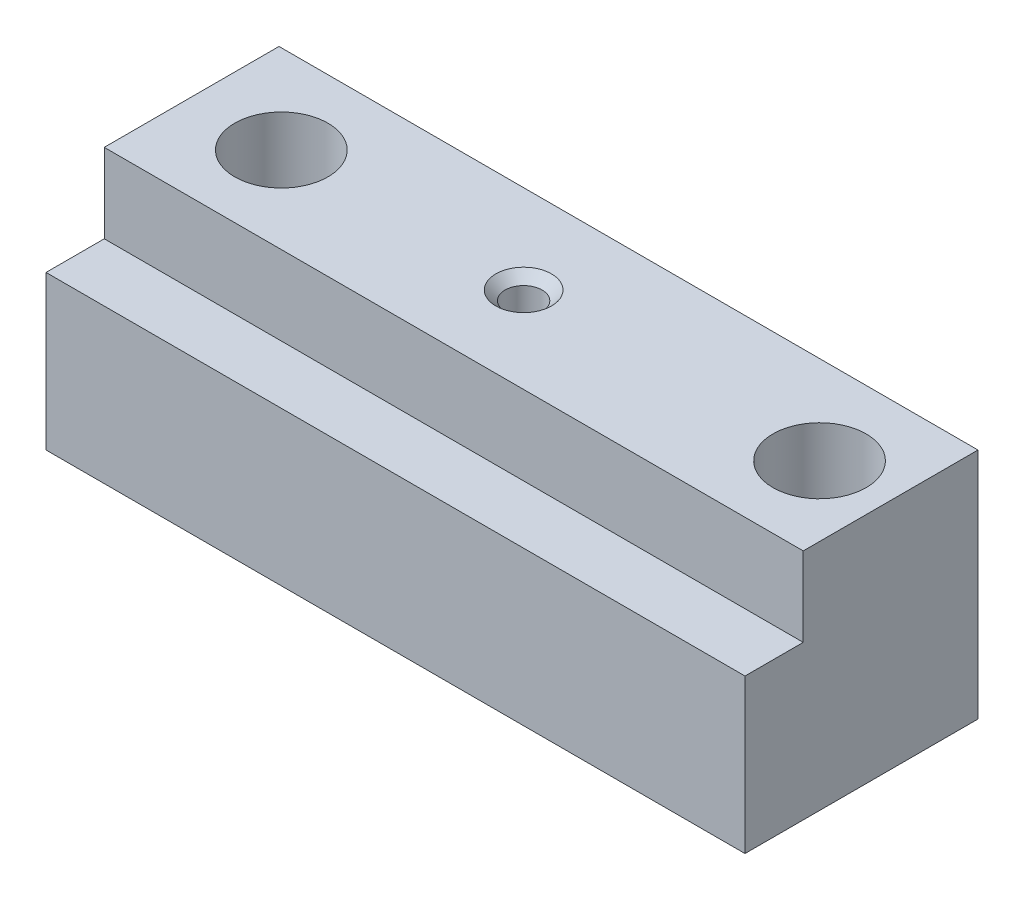
from build123d import *

# Parameters (mm, degrees)
BOSS_EXTRUDE1_DEPTH      = 38.1
BOSS_EXTRUDE1_DEPTH_BACK = 38.1
SKETCH2_R                = 5.08
CUT_EXTRUDE1_DEPTH       = 19.05
F_10_32_TAPPED_HOLE2_D   = 4.0386
CHAMFER5_SIZE            = 1.016
CHAMFER6_SIZE            = 1.016


with BuildPart() as part:
    # Sketch1 → Boss-Extrude1 (new, two sides: drawn at the far end of the back side and taken through both)
    with BuildSketch(Plane(origin=(0, 0, 0), x_dir=(0, 0, -1), z_dir=(1, 0, 0)).offset(-BOSS_EXTRUDE1_DEPTH_BACK)):
        Polygon((0, 0), (-6.35, 0), (-6.35, -16.764), (19.05, -16.764), (19.05, 8.636), (0, 8.636), align=None)
    extrude(amount=BOSS_EXTRUDE1_DEPTH + BOSS_EXTRUDE1_DEPTH_BACK)

    # Sketch2 → Cut-Extrude1 (cut)
    with BuildSketch(Plane(origin=(0, 8.636, 0), x_dir=(1, 0, 0), z_dir=(0, 1, 0))):
        with Locations((-28.194, 9.398)):
            Circle(SKETCH2_R)
        with Locations((30.48, 9.398)):
            Circle(SKETCH2_R)
    extrude(amount=-CUT_EXTRUDE1_DEPTH, mode=Mode.SUBTRACT)

    # 10-32 Tapped Hole2 (through all)
    with Locations(Plane(origin=(-1.778, 8.636, -9.398), x_dir=(0, 0, 1), z_dir=(0, 1, 0))):
        with Locations((0, 0)):
            Hole(F_10_32_TAPPED_HOLE2_D / 2)

    # Chamfer5
    chamfer5_edges = [part.edges().sort_by_distance(p)[0] for p in [
        (-1.778, 8.636, -7.3787),
    ]]
    chamfer(chamfer5_edges, length=CHAMFER5_SIZE)

    # Chamfer6
    chamfer6_edges = [part.edges().sort_by_distance(p)[0] for p in [
        (-1.778, -16.764, -7.3787),
    ]]
    chamfer(chamfer6_edges, length=CHAMFER6_SIZE)


solid = part.part
